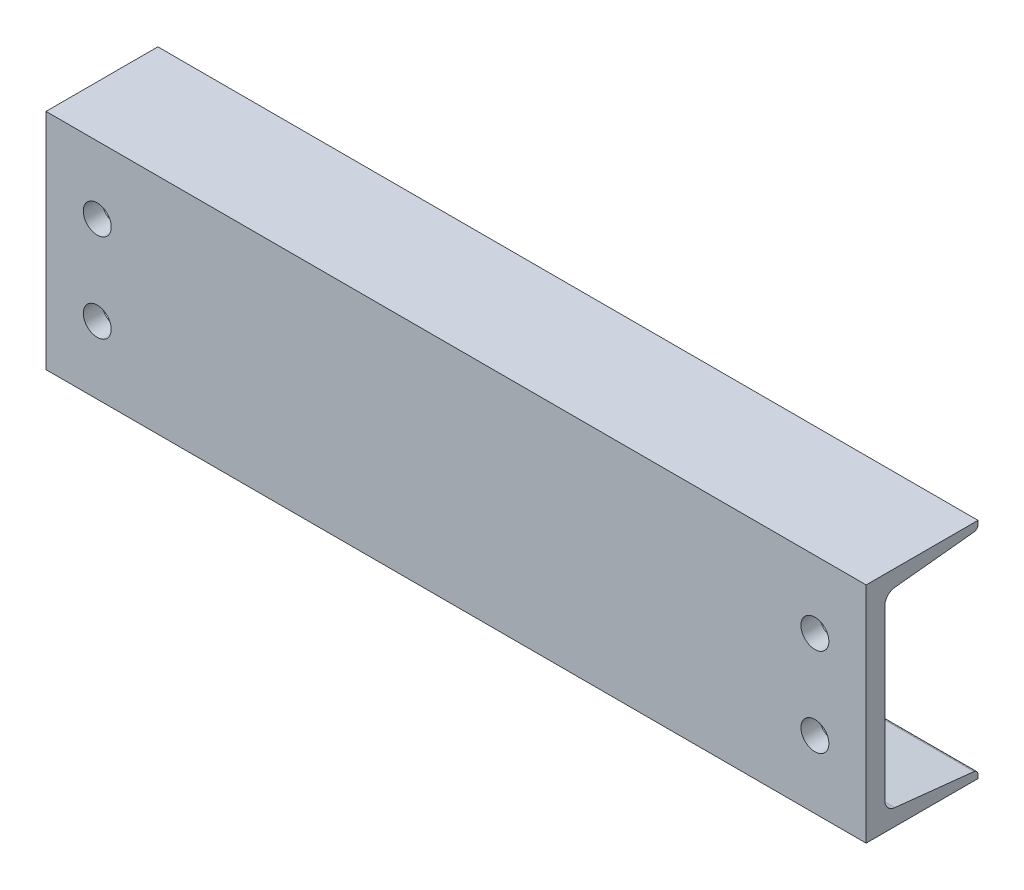
from build123d import *

# Parameters (mm, degrees)
BOSS_EXTRUDE1_DEPTH = 279.4
CUT_EXTRUDE1_REACH  = 78.2
SKETCH2_R           = 9.525
CUT_EXTRUDE2_REACH  = 154.4
SKETCH3_R           = 9.525


with BuildPart() as part:
    # Sketch1 → Boss-Extrude1 (new body, symmetric)
    with BuildSketch(Plane(origin=(0, 0, 0), x_dir=(0, 0, -1), z_dir=(1, 0, 0))):
        with BuildLine():
            Line((-48.8061, -76.2), (-48.8061, 76.2))
            Line((-48.8061, 76.2), (27.3939, 76.2))
            Line((27.3939, 76.2), (27.3939, 73.710744653))
            ThreePointArc((27.3939, 73.710744653), (26.61173954, 71.672050174), (24.666685315, 70.679672107))
            Line((24.666685315, 70.679672107), (-29.288063286, 64.969518115))
            ThreePointArc((-29.288063286, 64.969518115), (-34.150698849, 62.488572947), (-36.1061, 57.391836749))
            Line((-36.1061, 57.391836749), (-36.1061, -57.391836749))
            ThreePointArc((-36.1061, -57.391836749), (-34.150698849, -62.488572947), (-29.288063286, -64.969518115))
            Line((-29.288063286, -64.969518115), (24.666685315, -70.679672107))
            ThreePointArc((24.666685315, -70.679672107), (26.61173954, -71.672050174), (27.3939, -73.710744653))
            Line((27.3939, -73.710744653), (27.3939, -76.2))
            Line((27.3939, -76.2), (-48.8061, -76.2))
        make_face()
    extrude(amount=BOSS_EXTRUDE1_DEPTH, both=True)

    # Sketch2 → Cut-Extrude1 (cut, up to next)
    with BuildSketch(Plane.XY.offset(48.8061), mode=Mode.PRIVATE) as cut_extrude1_sk1:
        with Locations((-244.475, 30.1625)):
            Circle(SKETCH2_R)
    cut_extrude1_tool1 = extrude(cut_extrude1_sk1.sketch, amount=-CUT_EXTRUDE1_REACH, mode=Mode.PRIVATE) & part.part
    add(cut_extrude1_tool1.solids().sort_by_distance((-244.475, 30.1625, 48.8061))[0], mode=Mode.SUBTRACT)
    # Sketch2 → Cut-Extrude1 (cut, up to next)
    with BuildSketch(Plane.XY.offset(48.8061), mode=Mode.PRIVATE) as cut_extrude1_sk2:
        with Locations((-244.475, -30.1625)):
            Circle(SKETCH2_R)
    cut_extrude1_tool2 = extrude(cut_extrude1_sk2.sketch, amount=-CUT_EXTRUDE1_REACH, mode=Mode.PRIVATE) & part.part
    add(cut_extrude1_tool2.solids().sort_by_distance((-244.475, -30.1625, 48.8061))[0], mode=Mode.SUBTRACT)
    # Sketch2 → Cut-Extrude1 (cut, up to next)
    with BuildSketch(Plane.XY.offset(48.8061), mode=Mode.PRIVATE) as cut_extrude1_sk3:
        with Locations((244.475, -30.1625)):
            Circle(SKETCH2_R)
    cut_extrude1_tool3 = extrude(cut_extrude1_sk3.sketch, amount=-CUT_EXTRUDE1_REACH, mode=Mode.PRIVATE) & part.part
    add(cut_extrude1_tool3.solids().sort_by_distance((244.475, -30.1625, 48.8061))[0], mode=Mode.SUBTRACT)
    # Sketch2 → Cut-Extrude1 (cut, up to next)
    with BuildSketch(Plane.XY.offset(48.8061), mode=Mode.PRIVATE) as cut_extrude1_sk4:
        with Locations((244.475, 30.1625)):
            Circle(SKETCH2_R)
    cut_extrude1_tool4 = extrude(cut_extrude1_sk4.sketch, amount=-CUT_EXTRUDE1_REACH, mode=Mode.PRIVATE) & part.part
    add(cut_extrude1_tool4.solids().sort_by_distance((244.475, 30.1625, 48.8061))[0], mode=Mode.SUBTRACT)

    # Sketch3 → Cut-Extrude2 (cut, up to next)
    with BuildSketch(Plane.XZ.offset(76.2), mode=Mode.PRIVATE) as cut_extrude2_sk1:
        with Locations((-165.1, 10.7061)):
            Circle(SKETCH3_R)
    cut_extrude2_tool1 = extrude(cut_extrude2_sk1.sketch, amount=-CUT_EXTRUDE2_REACH, mode=Mode.PRIVATE) & part.part
    add(cut_extrude2_tool1.solids().sort_by_distance((-165.1, -76.2, 10.7061))[0], mode=Mode.SUBTRACT)
    # Sketch3 → Cut-Extrude2 (cut, up to next)
    with BuildSketch(Plane.XZ.offset(76.2), mode=Mode.PRIVATE) as cut_extrude2_sk2:
        with Locations((165.1, 10.7061)):
            Circle(SKETCH3_R)
    cut_extrude2_tool2 = extrude(cut_extrude2_sk2.sketch, amount=-CUT_EXTRUDE2_REACH, mode=Mode.PRIVATE) & part.part
    add(cut_extrude2_tool2.solids().sort_by_distance((165.1, -76.2, 10.7061))[0], mode=Mode.SUBTRACT)


solid = part.part
